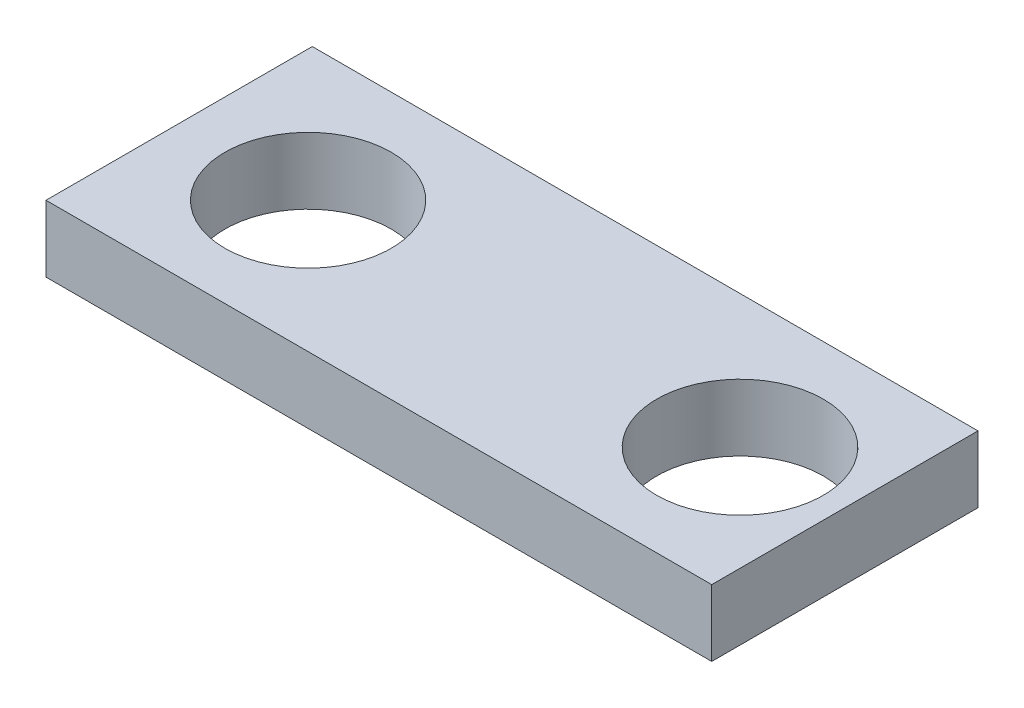
from build123d import *

# Parameters (mm, degrees)
SKETCH1_W           = 127
SKETCH1_H           = 50.8
BOSS_EXTRUDE1_DEPTH = 12.7
CUT_EXTRUDE1_DEPTH  = 12.7
CUT_EXTRUDE2_DEPTH  = 13.7


with BuildPart() as part:
    # Sketch1 → Boss-Extrude1 (new body)
    with BuildSketch(Plane(origin=(0, 0, 0), x_dir=(1, 0, 0), z_dir=(0, 1, 0))):
        with Locations((63.5, 25.4)):
            Rectangle(SKETCH1_W, SKETCH1_H)
    extrude(amount=BOSS_EXTRUDE1_DEPTH)

    # Sketch2 → Cut-Extrude1 (cut)
    with BuildSketch(Plane(origin=(0, 12.7, 0), x_dir=(1, 0, 0), z_dir=(0, 1, 0))):
        with BuildLine():
            ThreePointArc((9.125, 25), (13.774679849, 13.774679849), (25, 9.125))
            Line((25, 9.125), (25, 25))
            Line((25, 25), (9.125, 25))
        make_face()
        with BuildLine():
            Line((25, 25), (25, 9.125))
            ThreePointArc((25, 9.125), (36.225320151, 13.774679849), (40.875, 25))
            ThreePointArc((40.875, 25), (25, 40.875), (9.125, 25))
            Line((9.125, 25), (25, 25))
        make_face()
    extrude(amount=-CUT_EXTRUDE1_DEPTH, mode=Mode.SUBTRACT)

    # Sketch4 → Cut-Extrude2 (cut, through all)
    with BuildSketch(Plane(origin=(0, 12.7, 0), x_dir=(1, 0, 0), z_dir=(0, 1, 0))):
        with BuildLine():
            ThreePointArc((91.1, 25.4), (95.757002179, 14.157002179), (107, 9.5))
            Line((107, 9.5), (107, 25.4))
            Line((107, 25.4), (91.1, 25.4))
        make_face()
        with BuildLine():
            Line((107, 25.4), (107, 9.5))
            ThreePointArc((107, 9.5), (118.242997821, 14.157002179), (122.9, 25.4))
            ThreePointArc((122.9, 25.4), (107, 41.3), (91.1, 25.4))
            Line((91.1, 25.4), (107, 25.4))
        make_face()
    extrude(amount=-CUT_EXTRUDE2_DEPTH, mode=Mode.SUBTRACT)


solid = part.part
